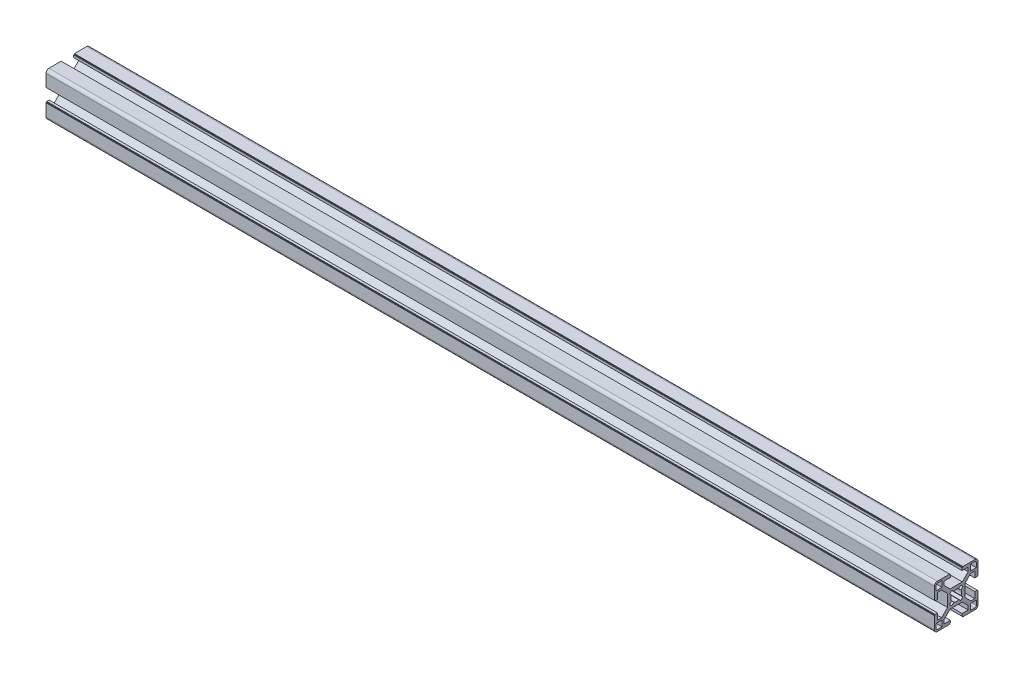
from build123d import *

# Parameters (mm, degrees)
BR_EXTRUDE_DEPTH      = 315
BR_EXTRUDE_DEPTH_BACK = 297


with BuildPart() as part:
    # Sketch2 → BR_Extrude (new body, two sides)
    with BuildSketch(Plane(origin=(0, 0, 0), x_dir=(0, 0, -1), z_dir=(1, 0, 0))) as br_extrude_sk:
        with BuildLine():
            Line((-6, 4.196877708), (-10.053122292, 8.25))
            Line((-10.053122292, 8.25), (-12.8, 8.25))
            Line((-12.8, 8.25), (-12.800036742, 4.05))
            Line((-12.800036742, 4.05), (-14.5, 4.05))
            Line((-14.5, 4.05), (-14.5, 4.55))
            Line((-14.5, 4.55), (-15, 4.55))
            Line((-15, 4.55), (-15, 13))
            ThreePointArc((-15, 13), (-14.414213562, 14.414213562), (-13, 15))
            Line((-13, 15), (-4.55, 15))
            Line((-4.55, 15), (-4.55, 14.5))
            Line((-4.55, 14.5), (-4.05, 14.5))
            Line((-4.05, 14.5), (-4.05, 12.800036742))
            Line((-4.05, 12.800036742), (-8.25, 12.8))
            Line((-8.25, 12.8), (-8.25, 10.053122292))
            Line((-8.25, 10.053122292), (-4.196877708, 6))
            Line((-4.196877708, 6), (4.196877708, 6))
            Line((4.196877708, 6), (8.25, 10.053122292))
            Line((8.25, 10.053122292), (8.25, 12.8))
            Line((8.25, 12.8), (4.05, 12.800036742))
            Line((4.05, 12.800036742), (4.05, 14.5))
            Line((4.05, 14.5), (4.55, 14.5))
            Line((4.55, 14.5), (4.55, 15))
            Line((4.55, 15), (13, 15))
            ThreePointArc((13, 15), (14.414213562, 14.414213562), (15, 13))
            Line((15, 13), (15, 4.55))
            Line((15, 4.55), (14.5, 4.55))
            Line((14.5, 4.55), (14.5, 4.05))
            Line((14.5, 4.05), (12.800036742, 4.05))
            Line((12.800036742, 4.05), (12.8, 8.25))
            Line((12.8, 8.25), (10.053122292, 8.25))
            Line((10.053122292, 8.25), (6, 4.196877708))
            Line((6, 4.196877708), (6, -4.196877708))
            Line((6, -4.196877708), (10.053122292, -8.25))
            Line((10.053122292, -8.25), (12.8, -8.25))
            Line((12.8, -8.25), (12.800036742, -4.05))
            Line((12.800036742, -4.05), (14.5, -4.05))
            Line((14.5, -4.05), (14.5, -4.55))
            Line((14.5, -4.55), (15, -4.55))
            Line((15, -4.55), (15, -13))
            ThreePointArc((15, -13), (14.414213562, -14.414213562), (13, -15))
            Line((13, -15), (4.55, -15))
            Line((4.55, -15), (4.55, -14.5))
            Line((4.55, -14.5), (4.05, -14.5))
            Line((4.05, -14.5), (4.05, -12.800036742))
            Line((4.05, -12.800036742), (8.25, -12.8))
            Line((8.25, -12.8), (8.25, -10.053122292))
            Line((8.25, -10.053122292), (4.196877708, -6))
            Line((4.196877708, -6), (-4.196877708, -6))
            Line((-4.196877708, -6), (-8.25, -10.053122292))
            Line((-8.25, -10.053122292), (-8.25, -12.8))
            Line((-8.25, -12.8), (-4.05, -12.800036742))
            Line((-4.05, -12.800036742), (-4.05, -14.5))
            Line((-4.05, -14.5), (-4.55, -14.5))
            Line((-4.55, -14.5), (-4.55, -15))
            Line((-4.55, -15), (-13, -15))
            ThreePointArc((-13, -15), (-14.414213562, -14.414213562), (-15, -13))
            Line((-15, -13), (-15, -4.55))
            Line((-15, -4.55), (-14.5, -4.55))
            Line((-14.5, -4.55), (-14.5, -4.05))
            Line((-14.5, -4.05), (-12.800036742, -4.05))
            Line((-12.800036742, -4.05), (-12.8, -8.25))
            Line((-12.8, -8.25), (-10.053122292, -8.25))
            Line((-10.053122292, -8.25), (-6, -4.196877708))
            Line((-6, -4.196877708), (-6, 4.196877708))
        make_face()
        with BuildLine():
            Line((-13.85, -9.7), (-13.85, -12.85))
            ThreePointArc((-13.85, -12.85), (-13.557106781, -13.557106781), (-12.85, -13.85))
            Line((-12.85, -13.85), (-9.7, -13.85))
            Line((-9.7, -13.85), (-9.7, -9.7))
            Line((-9.7, -9.7), (-13.85, -9.7))
        make_face(mode=Mode.SUBTRACT)
        with BuildLine():
            Line((9.7, -13.85), (12.85, -13.85))
            ThreePointArc((12.85, -13.85), (13.557106781, -13.557106781), (13.85, -12.85))
            Line((13.85, -12.85), (13.85, -9.7))
            Line((13.85, -9.7), (9.7, -9.7))
            Line((9.7, -9.7), (9.7, -13.85))
        make_face(mode=Mode.SUBTRACT)
        with BuildLine():
            Line((13.85, 9.7), (13.85, 12.85))
            ThreePointArc((13.85, 12.85), (13.557106781, 13.557106781), (12.85, 13.85))
            Line((12.85, 13.85), (9.7, 13.85))
            Line((9.7, 13.85), (9.7, 9.7))
            Line((9.7, 9.7), (13.85, 9.7))
        make_face(mode=Mode.SUBTRACT)
        with BuildLine():
            Line((-9.7, 13.85), (-12.85, 13.85))
            ThreePointArc((-12.85, 13.85), (-13.557106781, 13.557106781), (-13.85, 12.85))
            Line((-13.85, 12.85), (-13.85, 9.7))
            Line((-13.85, 9.7), (-9.7, 9.7))
            Line((-9.7, 9.7), (-9.7, 13.85))
        make_face(mode=Mode.SUBTRACT)
        with BuildLine():
            Line((-3.272394192, -1.616767223), (-4.59052283, -3.187651763))
            Line((-4.59052283, -3.187651763), (-3.187651763, -4.59052283))
            Line((-3.187651763, -4.59052283), (-1.616767223, -3.272394192))
            ThreePointArc((-1.616767223, -3.272394192), (0, -3.65), (1.616767223, -3.272394192))
            Line((1.616767223, -3.272394192), (3.187651763, -4.59052283))
            Line((3.187651763, -4.59052283), (4.59052283, -3.187651763))
            Line((4.59052283, -3.187651763), (3.272394192, -1.616767223))
            ThreePointArc((3.272394192, -1.616767223), (3.65, 0), (3.272394192, 1.616767223))
            Line((3.272394192, 1.616767223), (4.59052283, 3.187651763))
            Line((4.59052283, 3.187651763), (3.187651763, 4.59052283))
            Line((3.187651763, 4.59052283), (1.616767223, 3.272394192))
            ThreePointArc((1.616767223, 3.272394192), (0, 3.65), (-1.616767223, 3.272394192))
            Line((-1.616767223, 3.272394192), (-3.187651763, 4.59052283))
            Line((-3.187651763, 4.59052283), (-4.59052283, 3.187651763))
            Line((-4.59052283, 3.187651763), (-3.272394192, 1.616767223))
            ThreePointArc((-3.272394192, 1.616767223), (-3.65, 0), (-3.272394192, -1.616767223))
        make_face(mode=Mode.SUBTRACT)
    extrude(amount=BR_EXTRUDE_DEPTH)
    extrude(br_extrude_sk.sketch, amount=-BR_EXTRUDE_DEPTH_BACK)


solid = part.part
